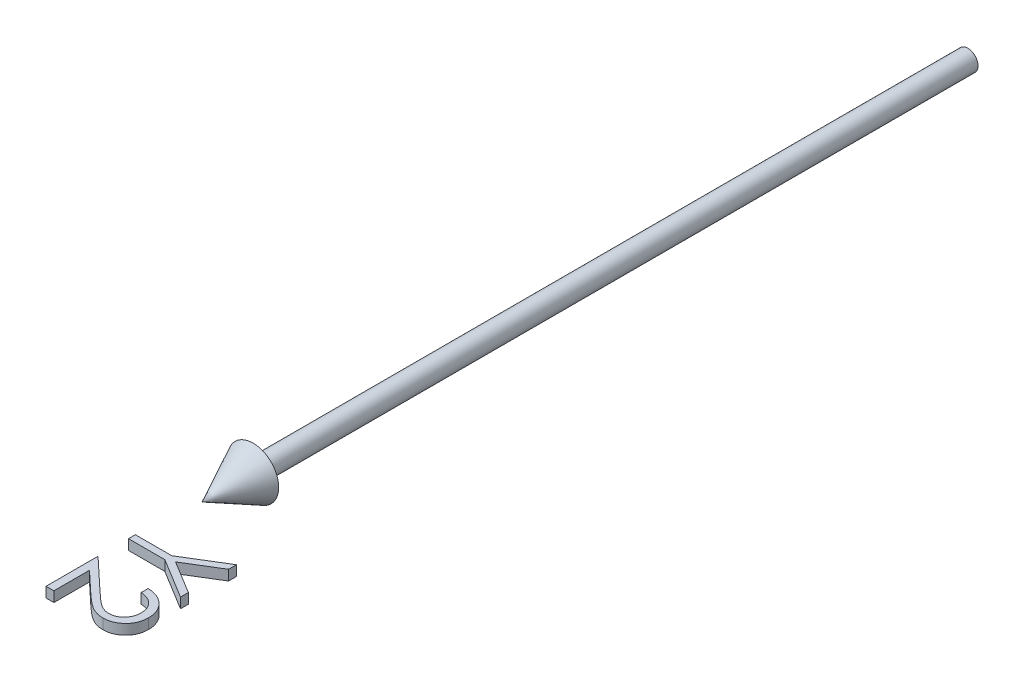
from build123d import *

# Parameters (mm, degrees)
BOSS_EXTRUDE1_DEPTH        = 1
BOSS_EXTRUDE1_DEPTH_BACK   = 1
BOSS_EXTRUDE1_2_DEPTH      = 1
BOSS_EXTRUDE1_2_DEPTH_BACK = 1


with BuildPart() as part:
    # Sketch2 → Revolve1 (revolve)
    with BuildSketch(Plane(origin=(0, 0, 0), x_dir=(1, 0, 0), z_dir=(0, 1, 0))):
        Polygon((0, -150), (5, -140), (2, -140), (2, 0), (0, 0), align=None)
    revolve(axis=Axis((0, 0, -41.949952025), (0, 0, 1)))


with BuildPart() as body_2:
    # Sketch3 → Boss-Extrude1 (new, two sides: drawn at the far end of the back side and taken through both)
    with BuildSketch(Plane(origin=(0, 0, 0), x_dir=(1, 0, 0), z_dir=(0, 1, 0)).offset(-BOSS_EXTRUDE1_DEPTH_BACK)):
        Polygon((15, -158.269230769), (15, -159.810697115), (8.5546875, -163.753004808), (15, -167.689302885), (15, -169.230769231), (7.130408654, -164.423076923), (0, -164.423076923), (0, -163.076923077), (7.130408654, -163.076923077), align=None)
    extrude(amount=BOSS_EXTRUDE1_DEPTH + BOSS_EXTRUDE1_DEPTH_BACK)


with BuildPart() as body_3:
    # Sketch3 → Boss-Extrude1 2 (new, two sides: drawn at the far end of the back side and taken through both)
    with BuildSketch(Plane(origin=(0, 0, 0), x_dir=(1, 0, 0), z_dir=(0, 1, 0)).offset(-BOSS_EXTRUDE1_2_DEPTH_BACK)):
        with BuildLine():
            Line((10.384615385, -172.307692308), (10.384615385, -170.961538462))
            add(Edge.make_bspline(
                [(10.384615385, -170.961538462), (10.563205784, -170.970310481), (10.913952575, -170.987538494), (11.425328289, -171.068252293), (11.914179653, -171.183636718), (12.376315664, -171.347163365), (12.817256926, -171.549104485), (13.231148249, -171.796338855), (13.622097454, -172.08359584), (13.982702577, -172.410348454), (14.312340745, -172.764905154), (14.600012522, -173.145141596), (14.840286171, -173.547149667), (15.042241714, -173.967442522), (15.193649809, -174.41088097), (15.306041475, -174.873226237), (15.373650782, -175.356568077), (15.380918932, -175.685882086), (15.384615385, -175.853365385)],
                knots=[0, 0, 0, 0, 1.100776268, 2.161895295, 3.184016182, 4.190939212, 5.176500551, 6.166955529, 7.155448256, 8.160289653, 9.16017456, 10.133824356, 11.091467644, 12.04088621, 13.000931625, 13.972173743, 14.968683325, 16, 16, 16, 16], degree=3))
            add(Edge.make_bspline(
                [(15.384615385, -175.853365385), (15.380764857, -176.017842845), (15.373198708, -176.341035179), (15.308222868, -176.812729527), (15.206456047, -177.261775075), (15.063675691, -177.687294074), (14.871742431, -178.085891494), (14.641181551, -178.460561685), (14.374525131, -178.815765159), (14.060580216, -179.135508518), (13.72542714, -179.429114572), (13.367621838, -179.682409951), (12.998067757, -179.899323508), (12.613946893, -180.080127851), (12.211642485, -180.213225589), (11.797011616, -180.314275052), (11.365762426, -180.371392539), (11.073877188, -180.38015864), (10.925480769, -180.384615385)],
                knots=[0, 0, 0, 0, 1.111607364, 2.184268762, 3.212621178, 4.221274766, 5.211760367, 6.196651075, 7.1921475, 8.207485113, 9.220403448, 10.201281604, 11.166441695, 12.114753415, 13.065576456, 14.026450734, 14.996634279, 16, 16, 16, 16], degree=3))
            add(Edge.make_bspline(
                [(10.925480769, -180.384615385), (10.716561478, -180.377358544), (10.302389134, -180.362972209), (9.693754008, -180.239910596), (9.104067926, -180.047711262), (8.629479489, -179.816294019), (8.24705023, -179.582840687), (7.932184351, -179.372465654), (7.593160915, -179.126187893), (7.231115184, -178.840422902), (6.843211305, -178.521082021), (6.42968361, -178.165272749), (5.994804597, -177.770457827), (5.697780591, -177.493349966), (5.543870192, -177.349759615)],
                knots=[0, 0, 0, 0, 1.184426356, 2.348067706, 3.509069118, 4.696110526, 5.333549288, 6.050745305, 6.844228056, 7.710549037, 8.667450064, 9.695053472, 10.805634456, 12, 12, 12, 12], degree=3))
            Line((5.543870192, -177.349759615), (1.538461538, -173.596754808))
            Line((1.538461538, -173.596754808), (1.538461538, -180.576923077))
            Line((1.538461538, -180.576923077), (0, -180.576923077))
            Line((0, -180.576923077), (0, -170.384615385))
            Line((0, -170.384615385), (6.207932692, -176.201923077))
            add(Edge.make_bspline(
                [(6.207932692, -176.201923077), (6.355774514, -176.343566905), (6.639748395, -176.615635711), (7.054467176, -177.000286256), (7.438755758, -177.346320011), (7.794317016, -177.653966516), (8.119135251, -177.923478904), (8.415755986, -178.153994855), (8.681633708, -178.346533206), (8.993975739, -178.550583737), (9.37577944, -178.745159458), (9.840016559, -178.916171607), (10.318969101, -179.019700036), (10.642533031, -179.032182668), (10.805288462, -179.038461538)],
                knots=[0, 0, 0, 0, 1.329530082, 2.553755191, 3.672934919, 4.687409497, 5.60679272, 6.413407421, 7.126401618, 7.737995624, 8.834647426, 9.90044882, 10.943907757, 12, 12, 12, 12], degree=3))
            add(Edge.make_bspline(
                [(10.805288462, -179.038461538), (10.907648622, -179.035764916), (11.109380842, -179.03045039), (11.404957531, -178.982658693), (11.691181234, -178.912443205), (11.964512999, -178.804219447), (12.230328736, -178.674192586), (12.480546816, -178.508073683), (12.723696572, -178.3182434), (12.951440602, -178.098049582), (13.160089498, -177.856317685), (13.344903048, -177.600905463), (13.499357413, -177.330692896), (13.625972124, -177.046806078), (13.725295262, -176.750039938), (13.794117725, -176.439819559), (13.837328376, -176.117002358), (13.843174826, -175.896573089), (13.846153846, -175.784254808)],
                knots=[0, 0, 0, 0, 0.991504627, 1.954065223, 2.895985987, 3.842598665, 4.797835564, 5.759220273, 6.74786863, 7.784730864, 8.824135544, 9.839918996, 10.835834653, 11.835434876, 12.84861661, 13.863796685, 14.911511676, 16, 16, 16, 16], degree=3))
            add(Edge.make_bspline(
                [(13.846153846, -175.784254808), (13.843090349, -175.666950718), (13.837074146, -175.436584855), (13.794963866, -175.098367814), (13.722386696, -174.775687596), (13.622884934, -174.467891001), (13.497611426, -174.174681471), (13.338567276, -173.898710207), (13.151962153, -173.637457681), (12.9392425, -173.391403722), (12.701290357, -173.165318738), (12.439301355, -172.962502138), (12.151571288, -172.789521018), (11.84459911, -172.63618104), (11.510222814, -172.518853263), (11.156545105, -172.418562608), (10.778541069, -172.345708862), (10.518104848, -172.320574965), (10.384615385, -172.307692308)],
                knots=[0, 0, 0, 0, 1.031212865, 2.025131798, 2.990757446, 3.934781266, 4.865570067, 5.788494791, 6.729227313, 7.684356718, 8.643577152, 9.610526866, 10.590658432, 11.59095419, 12.621640561, 13.700587263, 14.82141059, 16, 16, 16, 16], degree=3))
        make_face()
    extrude(amount=BOSS_EXTRUDE1_2_DEPTH + BOSS_EXTRUDE1_2_DEPTH_BACK)


solid = Compound([part.part, body_2.part, body_3.part])
